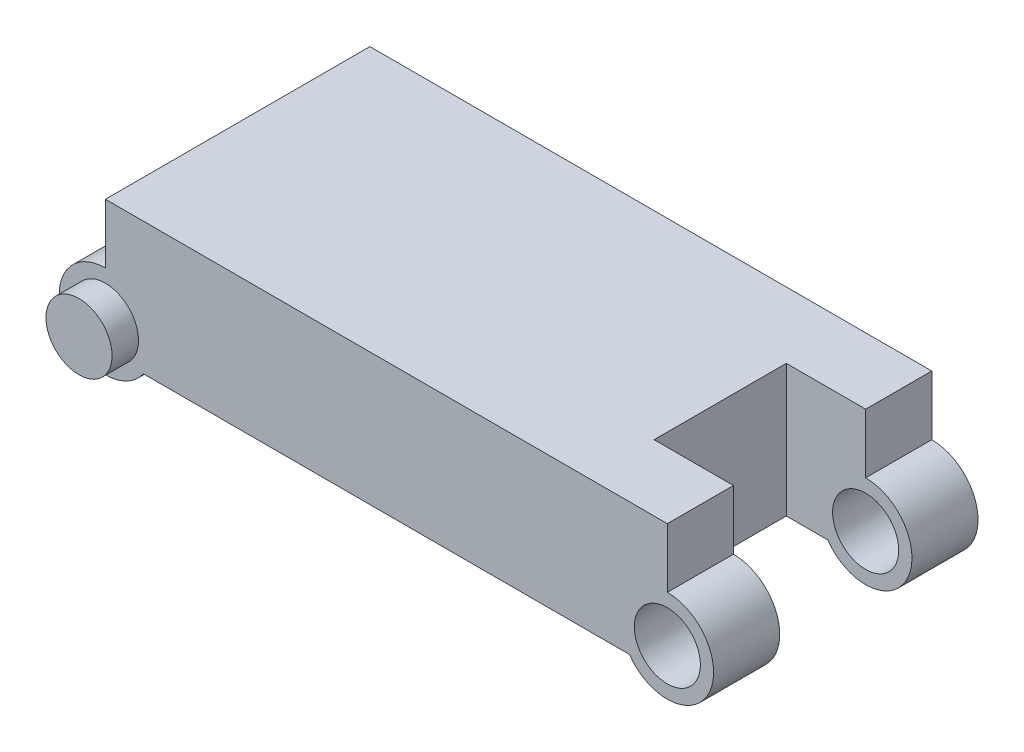
from build123d import *

# Parameters (mm, degrees)
SKETCH1_R                = 25
BOSS_EXTRUDE1_DEPTH      = 200
SKETCH2_R                = 25
BOSS_EXTRUDE2_DEPTH      = 20
BOSS_EXTRUDE2_DEPTH_BACK = 220
CUT_EXTRUDE1_START       = -50
SKETCH3_W                = 128.293241695
SKETCH3_H                = 120
CUT_EXTRUDE1_DEPTH       = 100


with BuildPart() as part:
    # Sketch1 → Boss-Extrude1 (new body)
    with BuildSketch(Plane.XY):
        with BuildLine():
            Line((28.722813233, -20), (396.277186767, -20))
            ThreePointArc((396.277186767, -20), (456.024184115, -16.201851746), (425, 35))
            Line((425, 35), (425, 80))
            Line((425, 80), (0, 80))
            Line((0, 80), (0, 35))
            ThreePointArc((0, 35), (-31.024184115, -16.201851746), (28.722813233, -20))
        make_face()
        with Locations((425, 0)):
            Circle(SKETCH1_R, mode=Mode.SUBTRACT)
    extrude(amount=BOSS_EXTRUDE1_DEPTH)

    # Sketch2 → Boss-Extrude2 (add, two sides)
    with BuildSketch(Plane.XY.offset(200)) as boss_extrude2_sk:
        Circle(SKETCH2_R)
    extrude(amount=BOSS_EXTRUDE2_DEPTH)
    extrude(boss_extrude2_sk.sketch, amount=-BOSS_EXTRUDE2_DEPTH_BACK)

    # Sketch3 → Cut-Extrude1 (cut)
    with BuildSketch(Plane.XY.offset(200).offset(CUT_EXTRUDE1_START)):
        with Locations((429.146620848, 20)):
            Rectangle(SKETCH3_W, SKETCH3_H)
    extrude(amount=-CUT_EXTRUDE1_DEPTH, mode=Mode.SUBTRACT)


solid = part.part
